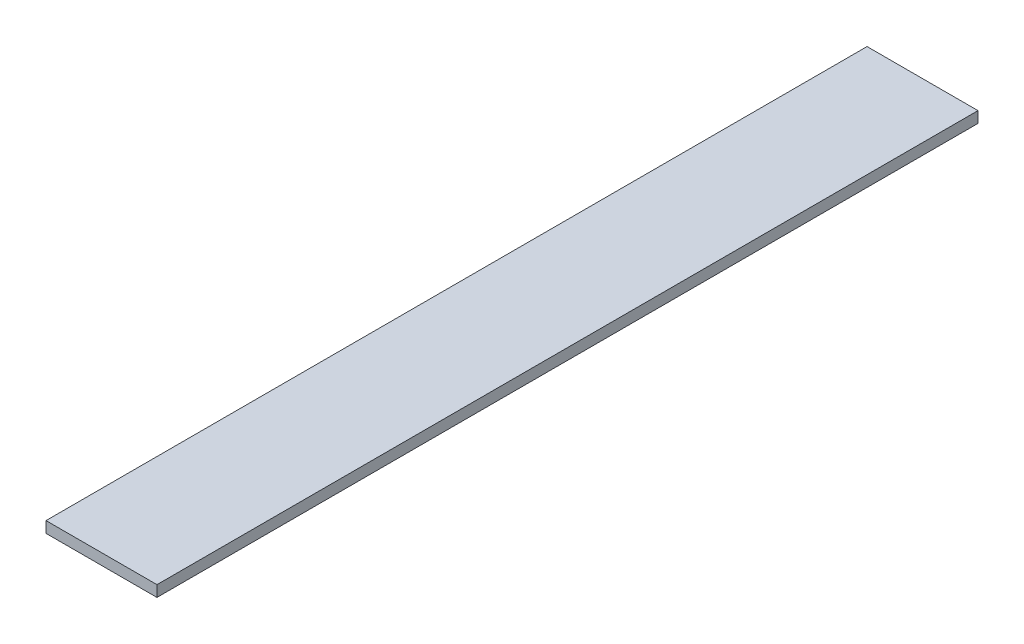
from build123d import *

# Parameters (mm, degrees)
SKETCH1_W           = 50
SKETCH1_H           = 370
BOSS_EXTRUDE1_DEPTH = 5


with BuildPart() as part:
    # Sketch1 → Boss-Extrude1 (new body)
    with BuildSketch(Plane(origin=(0, 0, 0), x_dir=(1, 0, 0), z_dir=(0, 1, 0))):
        with Locations((-25, 185)):
            Rectangle(SKETCH1_W, SKETCH1_H)
    extrude(amount=BOSS_EXTRUDE1_DEPTH)


solid = part.part
